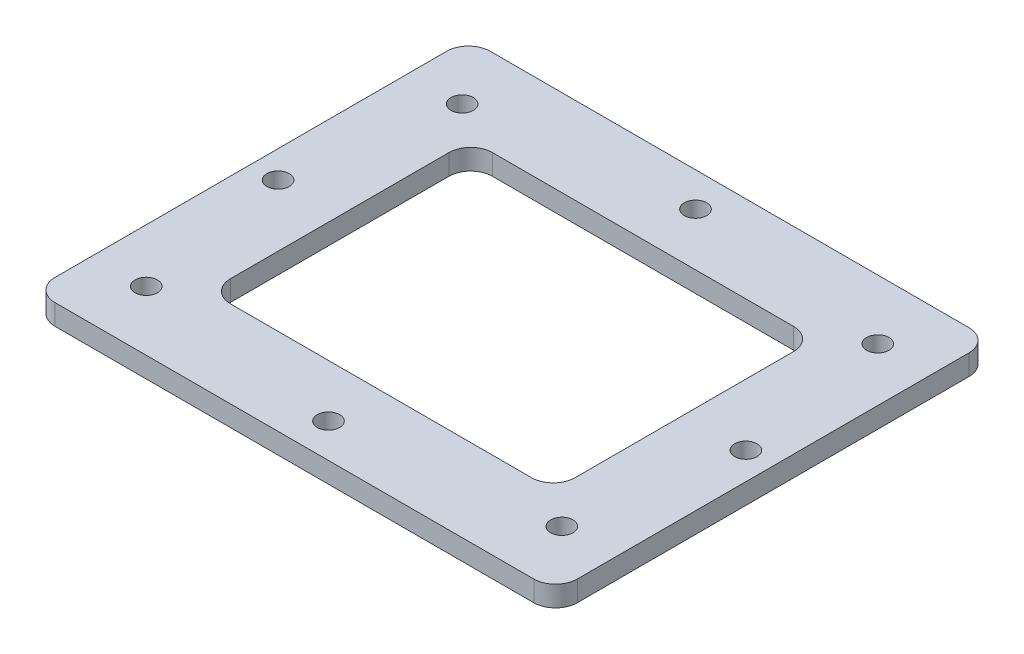
from build123d import *

# Parameters (mm, degrees)
SKETCH1_W                 = 76.2
SKETCH1_H                 = 63.5
SKETCH1_W_2               = 50.280812534
SKETCH1_H_2               = 38.222705752
BOSS_EXTRUDE1_DEPTH       = 1.5
FILLET1_R                 = 3.175
F_4_CLEARANCE_HOLE1_D     = 3.2639
F_4_CLEARANCE_HOLE1_DEPTH = 6.619425513
F_4_CLEARANCE_HOLE1_TIP   = 0.980574487


with BuildPart() as part:
    # Sketch1 → Boss-Extrude1 (new body, symmetric)
    with BuildSketch(Plane(origin=(0, 0, 0), x_dir=(1, 0, 0), z_dir=(0, 1, 0))):
        Rectangle(SKETCH1_W, SKETCH1_H)
        Rectangle(SKETCH1_W_2, SKETCH1_H_2, mode=Mode.SUBTRACT)
    extrude(amount=BOSS_EXTRUDE1_DEPTH, both=True)

    # Fillet1
    fillet1_edges = [part.edges().sort_by_distance(p)[0] for p in [
        (25.140406267, 0, 19.111352876),
        (25.140406267, 0, -19.111352876),
        (-25.140406267, 0, -19.111352876),
        (-25.140406267, 0, 19.111352876),
        (38.1, 0, 31.75),
        (-38.1, 0, 31.75),
        (-38.1, 0, -31.75),
        (38.1, 0, -31.75),
    ]]
    fillet(fillet1_edges, radius=FILLET1_R)

    # #4 Clearance Hole1
    with Locations(Plane(origin=(0, 1.5, 0), x_dir=(1, 0, 0), z_dir=(0, 1, 0))):
        with Locations((-34.125, 0), (-30.315, -23.045), (0, -26.77), (30.315, -23.045), (34.125, 0), (30.315, 23.045), (0, 26.77), (-30.315, 23.045)):
            Hole(F_4_CLEARANCE_HOLE1_D / 2, depth=F_4_CLEARANCE_HOLE1_DEPTH)
            with Locations((0, 0, -(F_4_CLEARANCE_HOLE1_DEPTH + F_4_CLEARANCE_HOLE1_TIP / 2))):  # 118° drill point
                Cone(0, F_4_CLEARANCE_HOLE1_D / 2, F_4_CLEARANCE_HOLE1_TIP, mode=Mode.SUBTRACT)


solid = part.part
